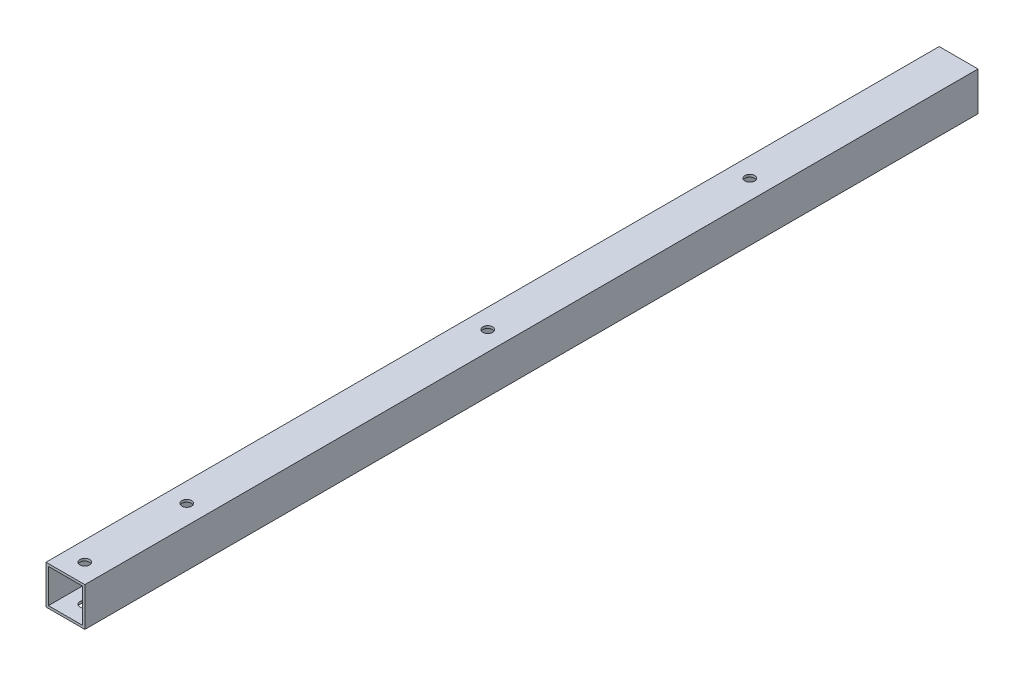
from build123d import *

# Parameters (mm, degrees)
SKETCH1_W           = 50.8
SKETCH1_H           = 50.8
SKETCH1_W_2         = 44.45
SKETCH1_H_2         = 44.45
EXTRUDE1_DEPTH      = 1117.6
EXTRUDE1_DEPTH_BACK = 50.8
SKETCH3_R           = 6.35
CUT_EXTRUDE2_DEPTH  = 51.8


with BuildPart() as part:
    # Sketch1 → Extrude1 (new body, two sides)
    with BuildSketch(Plane.XY) as extrude1_sk:
        with Locations((-514.35, 304.8)):
            Rectangle(SKETCH1_W, SKETCH1_H)
        with Locations((-514.35, 304.8)):
            Rectangle(SKETCH1_W_2, SKETCH1_H_2, mode=Mode.SUBTRACT)
    extrude(amount=EXTRUDE1_DEPTH)
    extrude(extrude1_sk.sketch, amount=-EXTRUDE1_DEPTH_BACK)

    # Sketch3 → Cut-Extrude2 (cut, through all)
    with BuildSketch(Plane(origin=(0, 330.2, 0), x_dir=(1, 0, 0), z_dir=(0, 1, 0))):
        with Locations((-514.35, -1092.2)):
            Circle(SKETCH3_R)
        with Locations((-514.35, -958.85)):
            Circle(SKETCH3_R)
        with Locations((-514.35, -565.15)):
            Circle(SKETCH3_R)
        with Locations((-514.35, -222.25)):
            Circle(SKETCH3_R)
    extrude(amount=-CUT_EXTRUDE2_DEPTH, mode=Mode.SUBTRACT)


solid = part.part
